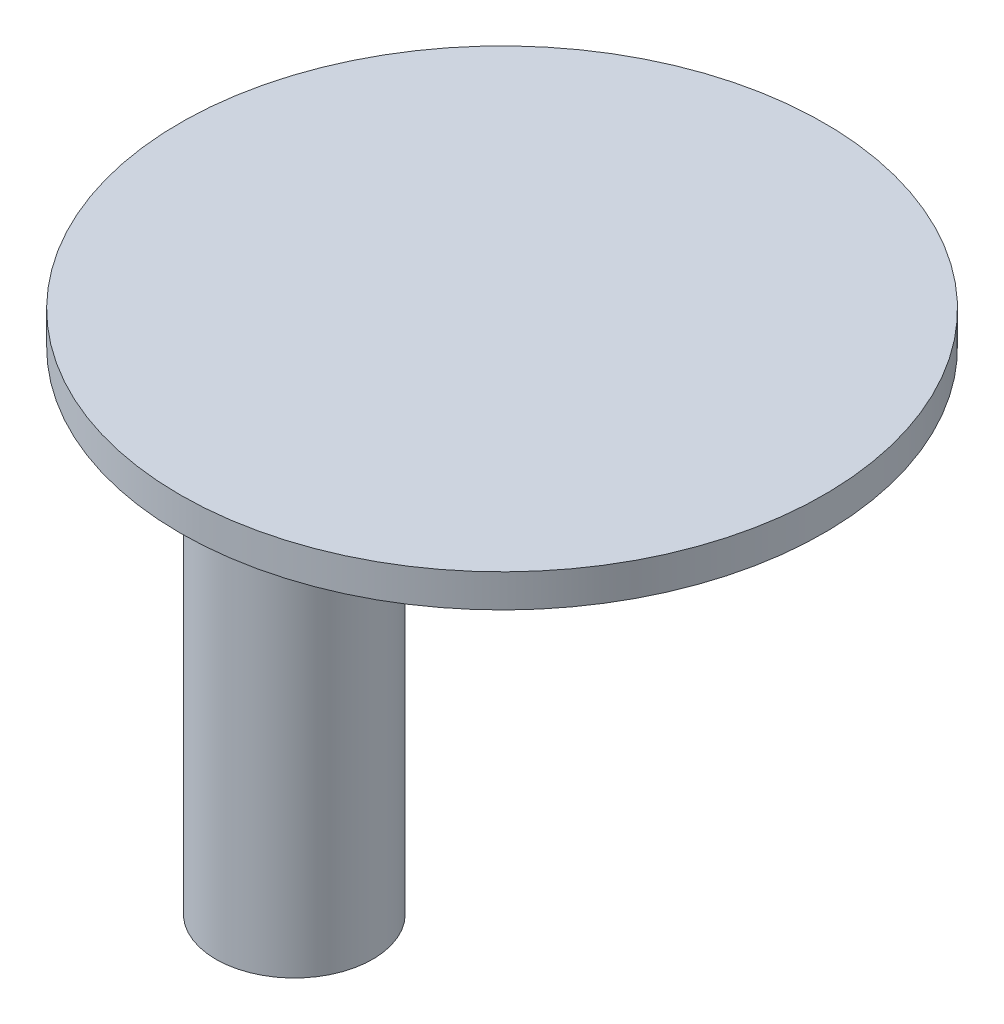
from build123d import *

# Parameters (mm, degrees)
SKETCH1_R           = 4.75
BOSS_EXTRUDE1_DEPTH = 32
SKETCH2_R           = 1.8
CUT_EXTRUDE1_DEPTH  = 3
SKETCH3_R           = 19.5
BOSS_EXTRUDE2_DEPTH = 2


with BuildPart() as part:
    # Sketch1 → Boss-Extrude1 (new body)
    with BuildSketch(Plane(origin=(0, 0, 0), x_dir=(1, 0, 0), z_dir=(0, 1, 0))):
        Circle(SKETCH1_R)
    extrude(amount=BOSS_EXTRUDE1_DEPTH)

    # Sketch2 → Cut-Extrude1 (cut)
    with BuildSketch(Plane.XZ):
        Circle(SKETCH2_R)
    extrude(amount=-CUT_EXTRUDE1_DEPTH, mode=Mode.SUBTRACT)

    # Sketch3 → Boss-Extrude2 (add)
    with BuildSketch(Plane(origin=(0, 32, 0), x_dir=(1, 0, 0), z_dir=(0, 1, 0))):
        with Locations((8.56, 4.02)):
            Circle(SKETCH3_R)
    extrude(amount=BOSS_EXTRUDE2_DEPTH)


solid = part.part
